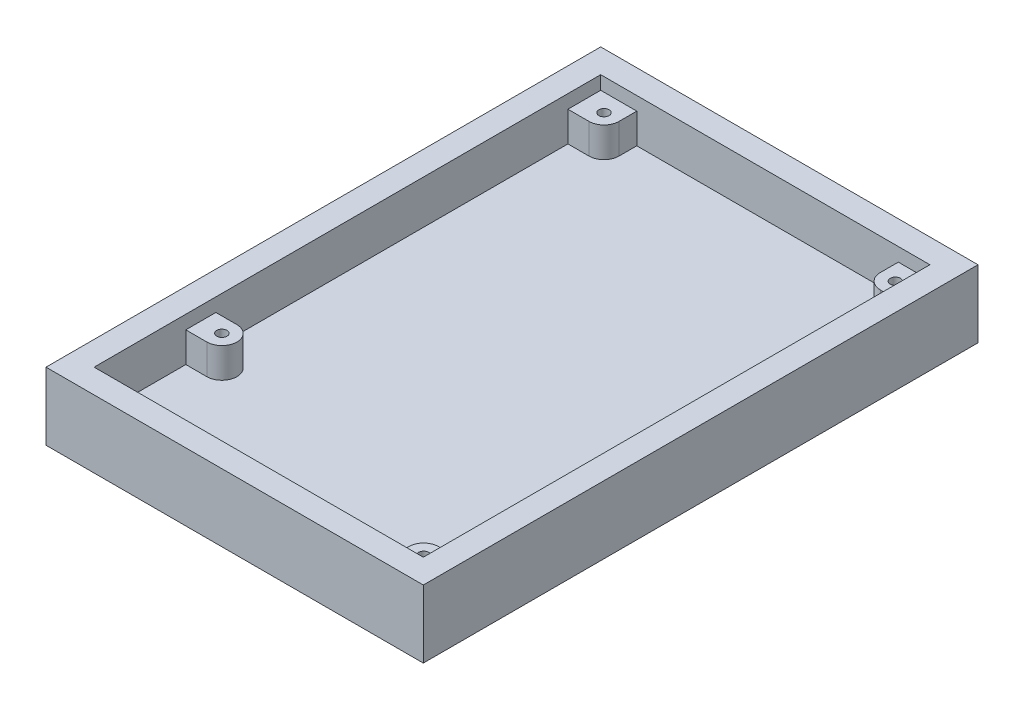
from build123d import *

# Parameters (mm, degrees)
SKETCH1_W           = 62.75
SKETCH1_H           = 92.25
BOSS_EXTRUDE1_DEPTH = 4
SKETCH2_W           = 62.75
SKETCH2_H           = 92.25
SKETCH2_W_2         = 54.75
SKETCH2_H_2         = 84.25
BOSS_EXTRUDE2_DEPTH = 7.25
SKETCH3_R           = 0.85
BOSS_EXTRUDE3_DEPTH = 5


with BuildPart() as part:
    # Sketch1 → Boss-Extrude1 (new body)
    with BuildSketch(Plane(origin=(0, 0, 0), x_dir=(1, 0, 0), z_dir=(0, 1, 0))):
        Rectangle(SKETCH1_W, SKETCH1_H)
    extrude(amount=BOSS_EXTRUDE1_DEPTH)

    # Sketch2 → Boss-Extrude2 (add)
    with BuildSketch(Plane(origin=(0, 4, 0), x_dir=(1, 0, 0), z_dir=(0, 1, 0))):
        Rectangle(SKETCH2_W, SKETCH2_H)
        Rectangle(SKETCH2_W_2, SKETCH2_H_2, mode=Mode.SUBTRACT)
    extrude(amount=BOSS_EXTRUDE2_DEPTH)

    # Sketch3 → Boss-Extrude3 (add)
    with BuildSketch(Plane(origin=(0, 4, 0), x_dir=(1, 0, 0), z_dir=(0, 1, 0))):
        with BuildLine():
            Line((-21.375, 39.175), (-21.375, 42.125))
            Line((-21.375, 42.125), (-27.375, 42.125))
            Line((-27.375, 42.125), (-27.375, 36.675))
            Line((-27.375, 36.675), (-23.875, 36.675))
            ThreePointArc((-23.875, 36.675), (-22.107233047, 37.407233047), (-21.375, 39.175))
        make_face()
        with Locations((-23.875, 39.175)):
            Circle(SKETCH3_R, mode=Mode.SUBTRACT)
        with BuildLine():
            Line((22.125, 39.125), (22.125, 42.125))
            Line((22.125, 42.125), (27.375, 42.125))
            Line((27.375, 42.125), (27.375, 36.625))
            Line((27.375, 36.625), (24.625, 36.625))
            ThreePointArc((24.625, 36.625), (22.857233047, 37.357233047), (22.125, 39.125))
        make_face()
        with Locations((24.625, 39.125)):
            Circle(SKETCH3_R, mode=Mode.SUBTRACT)
        with BuildLine():
            Line((22.375, -39.575), (22.375, -42.125))
            Line((22.375, -42.125), (27.375, -42.125))
            Line((27.375, -42.125), (27.375, -37.075))
            Line((27.375, -37.075), (24.875, -37.075))
            ThreePointArc((24.875, -37.075), (23.107233047, -37.807233047), (22.375, -39.575))
        make_face()
        with Locations((24.875, -39.575)):
            Circle(SKETCH3_R, mode=Mode.SUBTRACT)
        with BuildLine():
            Line((-23.875, -26.875), (-27.375, -26.875))
            Line((-27.375, -26.875), (-27.375, -21.875))
            Line((-27.375, -21.875), (-23.875, -21.875))
            ThreePointArc((-23.875, -21.875), (-21.375, -24.375), (-23.875, -26.875))
        make_face()
        with Locations((-23.875, -24.375)):
            Circle(SKETCH3_R, mode=Mode.SUBTRACT)
    extrude(amount=BOSS_EXTRUDE3_DEPTH)


solid = part.part
